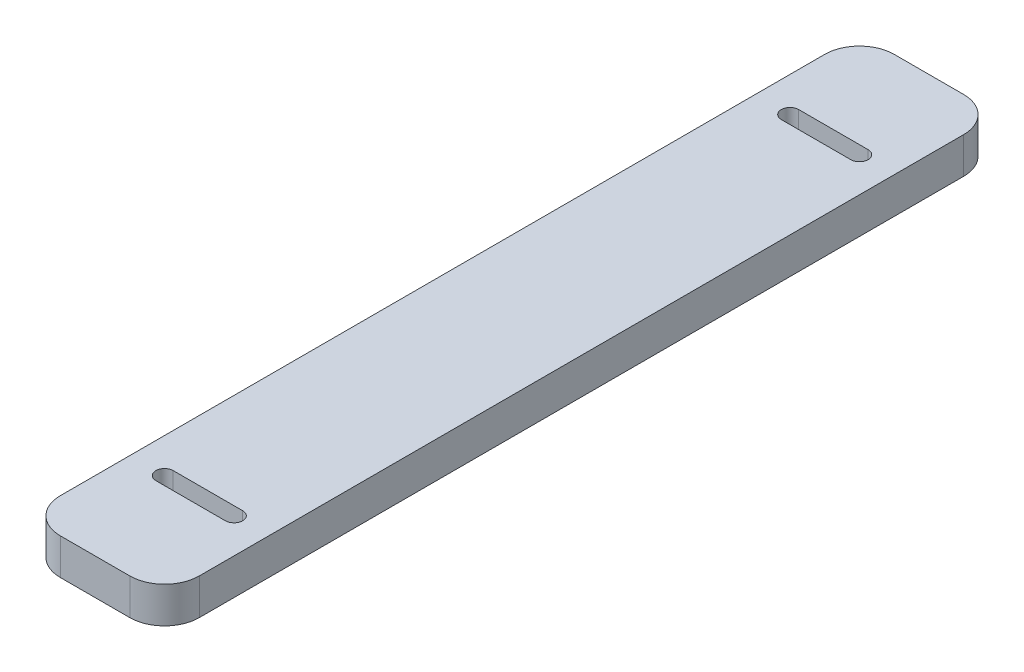
from build123d import *

# Parameters (mm, degrees)
SKETCH1_W           = 25.4
SKETCH1_H           = 152.4
BOSS_EXTRUDE1_DEPTH = 6.604
CUT_EXTRUDE1_DEPTH  = 7.604
FILLET1_R           = 6.35


with BuildPart() as part:
    # Sketch1 → Boss-Extrude1 (new body)
    with BuildSketch(Plane(origin=(0, 0, 0), x_dir=(1, 0, 0), z_dir=(0, 1, 0))):
        Rectangle(SKETCH1_W, SKETCH1_H)
    extrude(amount=BOSS_EXTRUDE1_DEPTH)

    # Sketch2 → Cut-Extrude1 (cut, through all)
    with BuildSketch(Plane(origin=(0, 6.604, 0), x_dir=(1, 0, 0), z_dir=(0, 1, 0))):
        with BuildLine():
            Line((-6.35, 58.7375), (6.35, 58.7375))
            ThreePointArc((6.35, 58.7375), (7.9375, 57.15), (6.35, 55.5625))
            Line((6.35, 55.5625), (-6.35, 55.5625))
            ThreePointArc((-6.35, 55.5625), (-7.9375, 57.15), (-6.35, 58.7375))
        make_face()
        with BuildLine():
            Line((-6.35, -55.5625), (6.35, -55.5625))
            ThreePointArc((6.35, -55.5625), (7.9375, -57.15), (6.35, -58.7375))
            Line((6.35, -58.7375), (-6.35, -58.7375))
            ThreePointArc((-6.35, -58.7375), (-7.9375, -57.15), (-6.35, -55.5625))
        make_face()
    extrude(amount=-CUT_EXTRUDE1_DEPTH, mode=Mode.SUBTRACT)

    # Fillet1
    fillet1_edges = [part.edges().sort_by_distance(p)[0] for p in [
        (-12.7, 3.302, -76.2),
        (12.7, 3.302, -76.2),
        (12.7, 3.302, 76.2),
        (-12.7, 3.302, 76.2),
    ]]
    fillet(fillet1_edges, radius=FILLET1_R)


solid = part.part
